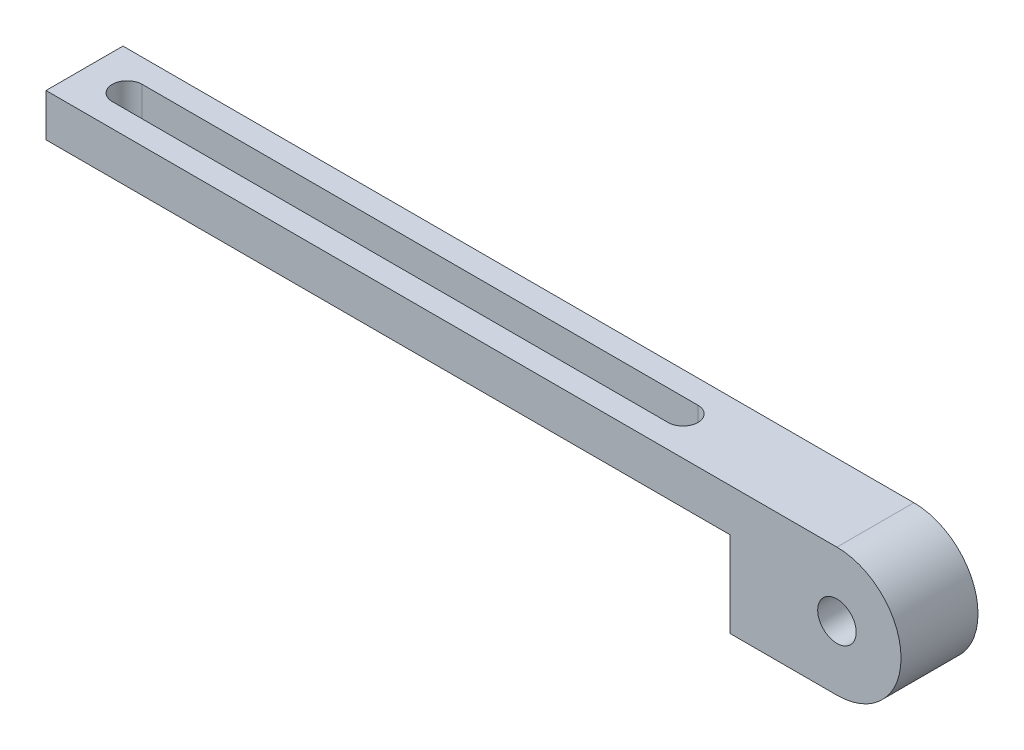
from build123d import *

# Parameters (mm, degrees)
SKETCH1_W           = 100
SKETCH1_H           = 9
BOSS_EXTRUDE1_DEPTH = 5
CUT_EXTRUDE1_DEPTH  = 6
SKETCH3_W           = 20
SKETCH3_H           = 15
BOSS_EXTRUDE2_DEPTH = 9
SKETCH4_R           = 2.25
CUT_EXTRUDE2_DEPTH  = 10


with BuildPart() as part:
    # Sketch1 → Boss-Extrude1 (new body)
    with BuildSketch(Plane(origin=(0, 0, 0), x_dir=(1, 0, 0), z_dir=(0, 1, 0))):
        with Locations((50, 4.5)):
            Rectangle(SKETCH1_W, SKETCH1_H)
    extrude(amount=BOSS_EXTRUDE1_DEPTH)

    # Sketch2 → Cut-Extrude1 (cut, through all)
    with BuildSketch(Plane(origin=(0, 5, 0), x_dir=(1, 0, 0), z_dir=(0, 1, 0))):
        with BuildLine():
            Line((5, 6.25), (70, 6.25))
            ThreePointArc((70, 6.25), (71.75, 4.5), (70, 2.75))
            Line((70, 2.75), (5, 2.75))
            ThreePointArc((5, 2.75), (3.25, 4.5), (5, 6.25))
        make_face()
    extrude(amount=-CUT_EXTRUDE1_DEPTH, mode=Mode.SUBTRACT)

    # Sketch3 → Boss-Extrude2 (add)
    with BuildSketch(Plane(origin=(0, 0, -9), x_dir=(-1, 0, 0), z_dir=(0, 0, -1))):
        with Locations((-90, -2.5)):
            Rectangle(SKETCH3_W, SKETCH3_H)
    extrude(amount=-BOSS_EXTRUDE2_DEPTH)

    # Sketch4 → Cut-Extrude2 (cut)
    with BuildSketch(Plane(origin=(0, 0, -9), x_dir=(-1, 0, 0), z_dir=(0, 0, -1))):
        with BuildLine():
            Line((-100, 5), (-100, -2.5))
            ThreePointArc((-100, -2.5), (-97.803300859, 2.803300859), (-92.5, 5))
            Line((-92.5, 5), (-100, 5))
        make_face()
        with BuildLine():
            Line((-100, -10), (-92.5, -10))
            ThreePointArc((-92.5, -10), (-97.803300859, -7.803300859), (-100, -2.5))
            Line((-100, -2.5), (-100, -10))
        make_face()
        with Locations((-92.5, -2.5)):
            Circle(SKETCH4_R)
    extrude(amount=-CUT_EXTRUDE2_DEPTH, mode=Mode.SUBTRACT)


solid = part.part
